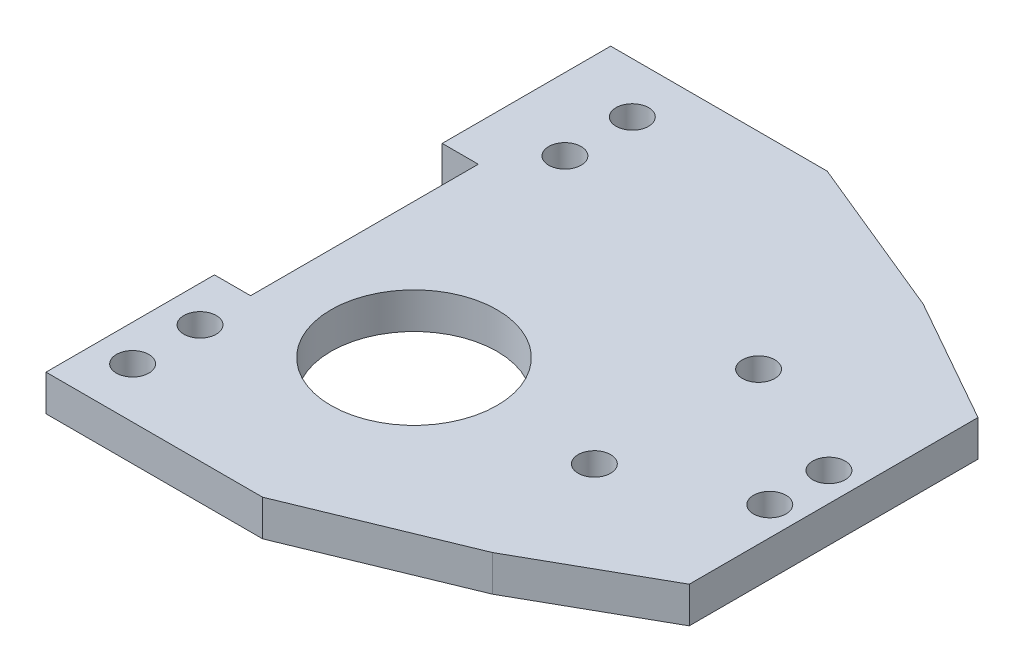
from build123d import *

# Parameters (mm, degrees)
SKETCH1_R           = 2.25
SKETCH1_R_2         = 11.5
BOSS_EXTRUDE1_DEPTH = 5


with BuildPart() as part:
    # Sketch1 → Boss-Extrude1 (new body)
    with BuildSketch(Plane.XZ.offset(5)):
        Polygon((-35.75064294, 15.774393454), (-35.75064294, -15.774393454), (-40.75064294, -15.774393454), (-40.75064294, -39.112565995), (-10.75064294, -39.112565995), (11.828174009, -29.823562546), (29.24935706, -20), (29.24935706, 20), (11.828174009, 29.823562546), (-10.75064294, 39.112565995), (-40.75064294, 39.112565995), (-40.75064294, 15.774393454), align=None)
        with Locations((-30.75064294, -22.774393454)):
            Circle(SKETCH1_R, mode=Mode.SUBTRACT)
        with Locations((25.272832985, -3.329685731)):
            Circle(SKETCH1_R, mode=Mode.SUBTRACT)
        with Locations((8.246602308, -10.606066633)):
            Circle(SKETCH1_R, mode=Mode.SUBTRACT)
        with Locations((25.272832985, 4.867552465)):
            Circle(SKETCH1_R, mode=Mode.SUBTRACT)
        with Locations((-30.75064294, -32.112565995)):
            Circle(SKETCH1_R, mode=Mode.SUBTRACT)
        with Locations((-17.003397692, 11.878643261)):
            Circle(SKETCH1_R_2, mode=Mode.SUBTRACT)
        with Locations((8.246602308, 12.143933367)):
            Circle(SKETCH1_R, mode=Mode.SUBTRACT)
        with Locations((-35.75064294, 22.774393454)):
            Circle(SKETCH1_R, mode=Mode.SUBTRACT)
        with Locations((-35.75064294, 32.112565995)):
            Circle(SKETCH1_R, mode=Mode.SUBTRACT)
    extrude(amount=-BOSS_EXTRUDE1_DEPTH)


solid = part.part
